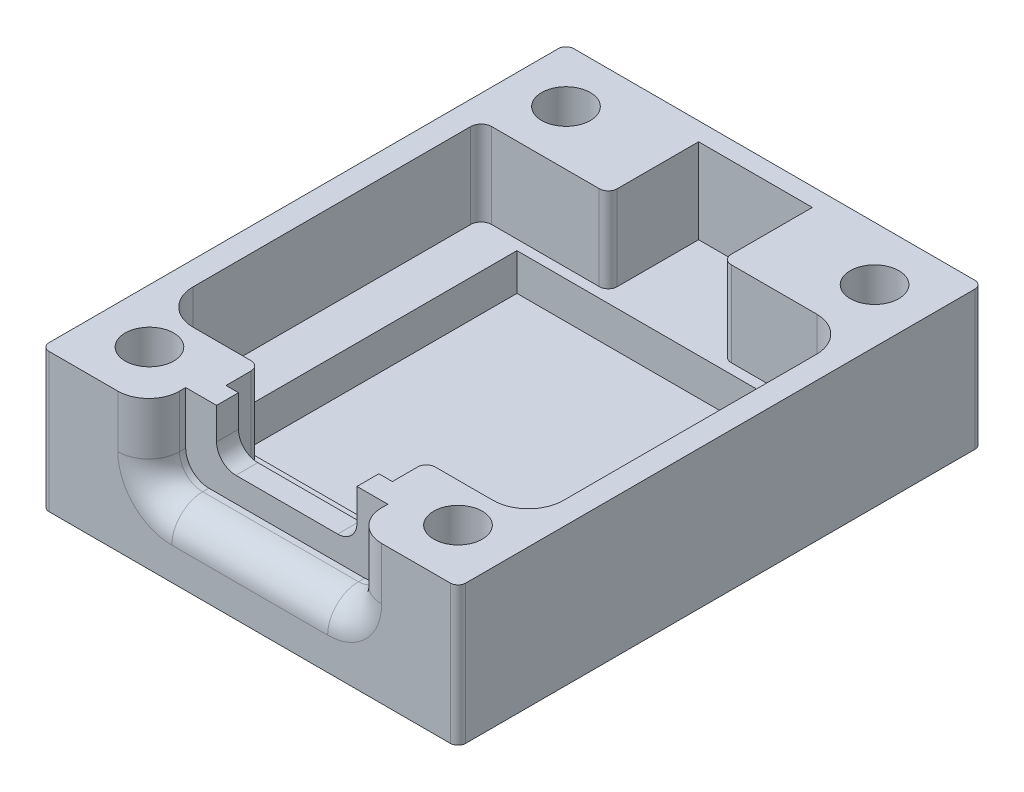
from build123d import *

# Parameters (mm, degrees)
SKETCH_1_W          = 27
SKETCH_1_H          = 34
EXTRUDE_1_DEPTH     = 9
CUT_EXTRUDE_1_DEPTH = 5.5
SKETCH_5_W          = 18
SKETCH_5_H          = 20
CUT_EXTRUDE_2_DEPTH = 2.4
SKETCH_7_W          = 9.1
SKETCH_7_H          = 3.3
CUT_EXTRUDE_3_DEPTH = 3.820001
CUT_EXTRUDE_4_DEPTH = 2.4
SKETCH_9_R          = 1.575
CUT_EXTRUDE_5_DEPTH = 3.1
FILLET_1_R          = 0.5
FILLET_2_R          = 1.5
FILLET_3_R          = 1.25
FILLET_4_R          = 2


with BuildPart() as part:
    # 草图1 → 凸台-拉伸1 (new body)
    with BuildSketch(Plane(origin=(0, 0, 0), x_dir=(1, 0, 0), z_dir=(0, 1, 0))):
        Rectangle(SKETCH_1_W, SKETCH_1_H)
    extrude(amount=EXTRUDE_1_DEPTH)

    # 草图3 → 切除-拉伸1 (cut)
    with BuildSketch(Plane(origin=(0, 9, 0), x_dir=(1, 0, 0), z_dir=(0, 1, 0))):
        with BuildLine():
            Line((-3.725034324, 15.819299777), (3.648970913, 15.819299777))
            Line((3.648970913, 15.819299777), (3.64896994, 10.554745119))
            ThreePointArc((3.64896994, 10.554745119), (3.822350515, 10.139234755), (4.241249073, 9.974209696))
            Line((4.241249073, 9.974209696), (9.783400257, 9.974209696))
            ThreePointArc((9.783400257, 9.974209696), (11.370154466, 9.295205446), (12.02766691, 7.699425674))
            Line((12.02766691, 7.699425674), (12.02766691, -8.683574325))
            ThreePointArc((12.02766691, -8.683574325), (11.356679802, -10.306708388), (9.731381036, -10.972434915))
            Line((9.731381036, -10.972434915), (5.988537145, -10.972434915))
            ThreePointArc((5.988537145, -10.972434915), (5.590573679, -11.145336005), (5.425084588, -11.546438321))
            Line((5.425084588, -11.546438321), (5.425084588, -13.179999201))
            Line((5.425084588, -13.179999201), (-5.361915412, -13.179999201))
            Line((-5.361915412, -13.179999201), (-5.361915412, -11.557540546))
            ThreePointArc((-5.361915412, -11.557540546), (-5.529636352, -11.146058241), (-5.93984312, -10.975241356))
            Line((-5.93984312, -10.975241356), (-9.683907212, -10.975243852))
            ThreePointArc((-9.683907212, -10.975243852), (-11.295675804, -10.308730473), (-11.96592401, -8.698511128))
            Line((-11.96592401, -8.698511128), (-11.965923922, 9.282882934))
            ThreePointArc((-11.965923922, 9.282882934), (-11.776218419, 9.756882394), (-11.311023769, 9.967257479))
            Line((-11.311023769, 9.967257479), (-4.318854243, 9.967257479))
            ThreePointArc((-4.318854243, 9.967257479), (-3.899962458, 10.130736448), (-3.725034039, 10.544977621))
            Line((-3.725034039, 10.544977621), (-3.725034324, 15.819299777))
        make_face()
    extrude(amount=-CUT_EXTRUDE_1_DEPTH, mode=Mode.SUBTRACT)

    # 草图5 → 切除-拉伸2 (cut)
    with BuildSketch(Plane(origin=(0, 3.5, 0), x_dir=(1, 0, 0), z_dir=(0, 1, 0))):
        with Locations((0, -0.680700223)):
            Rectangle(SKETCH_5_W, SKETCH_5_H)
    extrude(amount=-CUT_EXTRUDE_2_DEPTH, mode=Mode.SUBTRACT)

    # 草图7 → 切除-拉伸3 (cut)
    with BuildSketch(Plane.XY.offset(17)):
        with Locations((0, 7.35)):
            Rectangle(SKETCH_7_W, SKETCH_7_H)
    extrude(amount=-CUT_EXTRUDE_3_DEPTH, mode=Mode.SUBTRACT)

    # 草图8 → 切除-拉伸4 (cut)
    with BuildSketch(Plane.XY.offset(17)):
        Polygon((6.55, 4.1), (-6.55, 4.1), (-6.55, 9), (-4.55, 9), (4.55, 9), (6.55, 9), align=None)
    extrude(amount=-CUT_EXTRUDE_4_DEPTH, mode=Mode.SUBTRACT)

    # 草图9 → 切除-拉伸5 (cut)
    with BuildSketch(Plane(origin=(0, 9, 0), x_dir=(1, 0, 0), z_dir=(0, 1, 0))):
        with Locations((-10, 13.5)):
            Circle(SKETCH_9_R)
        with Locations((10, 13.5)):
            Circle(SKETCH_9_R)
        with Locations((10, -13.5)):
            Circle(SKETCH_9_R)
        with Locations((-10, -13.5)):
            Circle(SKETCH_9_R)
    extrude(amount=-CUT_EXTRUDE_5_DEPTH, mode=Mode.SUBTRACT)

    # 圆角1
    fillet_1_edges = [part.edges().sort_by_distance(p)[0] for p in [
        (13.5, 4.5, 17),
        (-13.5, 4.5, 17),
        (-13.5, 4.5, -17),
        (13.5, 4.5, -17),
    ]]
    fillet(fillet_1_edges, radius=FILLET_1_R)

    # 圆角2
    fillet_2_edges = [part.edges().sort_by_distance(p)[0] for p in [
        (6.55, 4.1, 15.8),
        (-6.55, 4.1, 15.8),
    ]]
    fillet(fillet_2_edges, radius=FILLET_2_R)

    # 圆角3
    fillet_3_edges = [part.edges().sort_by_distance(p)[0] for p in [
        (4.55, 5.7, 13.8899995),
        (-4.55, 5.7, 13.8899995),
    ]]
    fillet(fillet_3_edges, radius=FILLET_3_R)

    # 圆角4
    fillet_4_edges = [part.edges().sort_by_distance(p)[0] for p in [
        (-6.55, 7.3, 17),
        (6.55, 7.3, 17),
        (0, 4.1, 17),
        (6.110660172, 4.539339828, 17),
        (-6.110660172, 4.539339828, 17),
    ]]
    fillet(fillet_4_edges, radius=FILLET_4_R)


solid = part.part
